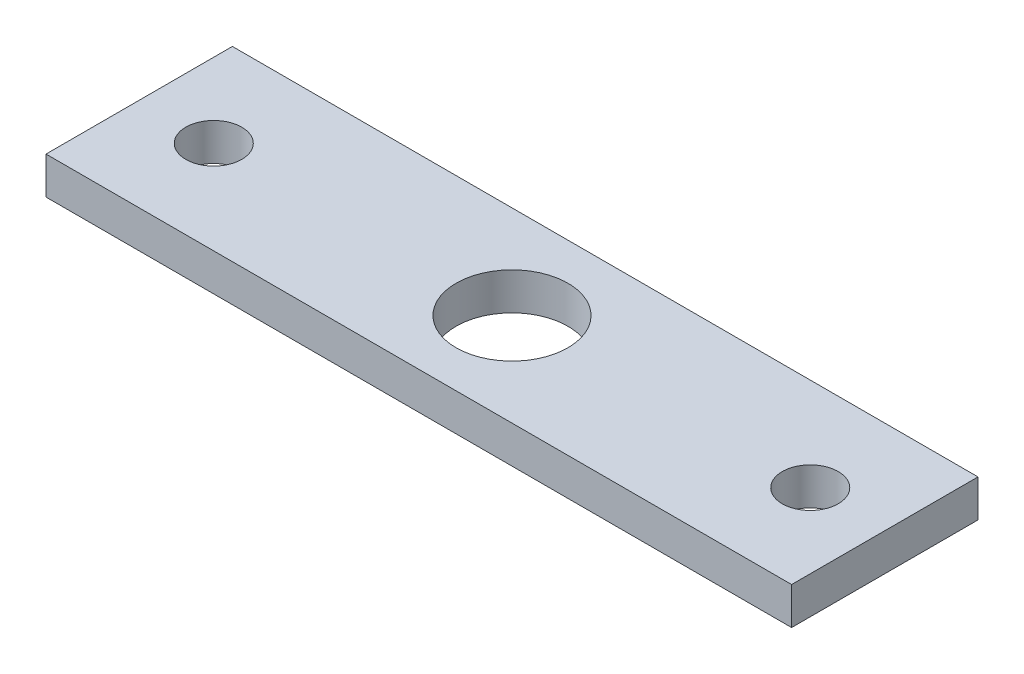
from build123d import *

# Parameters (mm, degrees)
SKETCH1_W           = 40
SKETCH1_H           = 10
BOSS_EXTRUDE1_DEPTH = 2
SKETCH2_R           = 1.5
SKETCH2_R_2         = 3
CUT_EXTRUDE1_DEPTH  = 3


with BuildPart() as part:
    # Sketch1 → Boss-Extrude1 (new body)
    with BuildSketch(Plane(origin=(0, 0, 0), x_dir=(1, 0, 0), z_dir=(0, 1, 0))):
        with Locations((-13.333333333, 0.131578947)):
            Rectangle(SKETCH1_W, SKETCH1_H)
    extrude(amount=BOSS_EXTRUDE1_DEPTH)

    # Sketch2 → Cut-Extrude1 (cut, through all)
    with BuildSketch(Plane(origin=(0, 2, 0), x_dir=(1, 0, 0), z_dir=(0, 1, 0))):
        with Locations((-29.333333333, 0.131578947)):
            Circle(SKETCH2_R)
        with Locations((2.666666667, 0.131578947)):
            Circle(SKETCH2_R)
        with Locations((-13.333333333, 0.131578947)):
            Circle(SKETCH2_R_2)
    extrude(amount=-CUT_EXTRUDE1_DEPTH, mode=Mode.SUBTRACT)


solid = part.part
